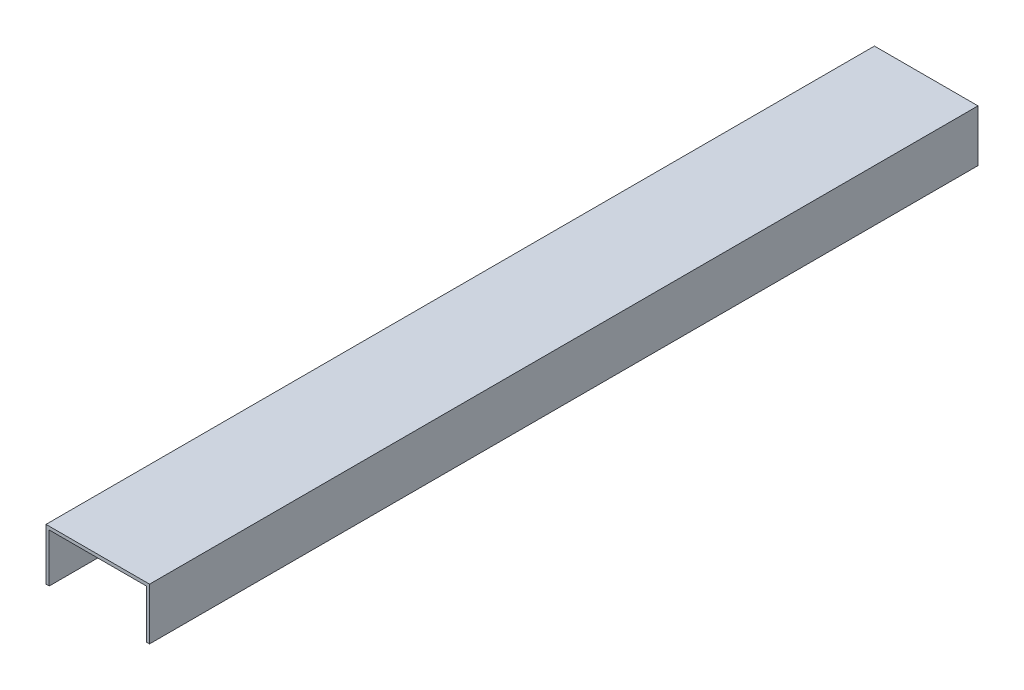
from build123d import *

# Parameters (mm, degrees)
BOSS_EXTRUDE1_DEPTH = 812.8


with BuildPart() as part:
    # Sketch1 → Boss-Extrude1 (new body)
    with BuildSketch(Plane.XY):
        Polygon((3.175, 0), (3.175, 47.625), (98.425, 47.625), (98.425, 0), (101.6, 0), (101.6, 50.8), (0, 50.8), (0, 0), align=None)
    extrude(amount=BOSS_EXTRUDE1_DEPTH)


solid = part.part
